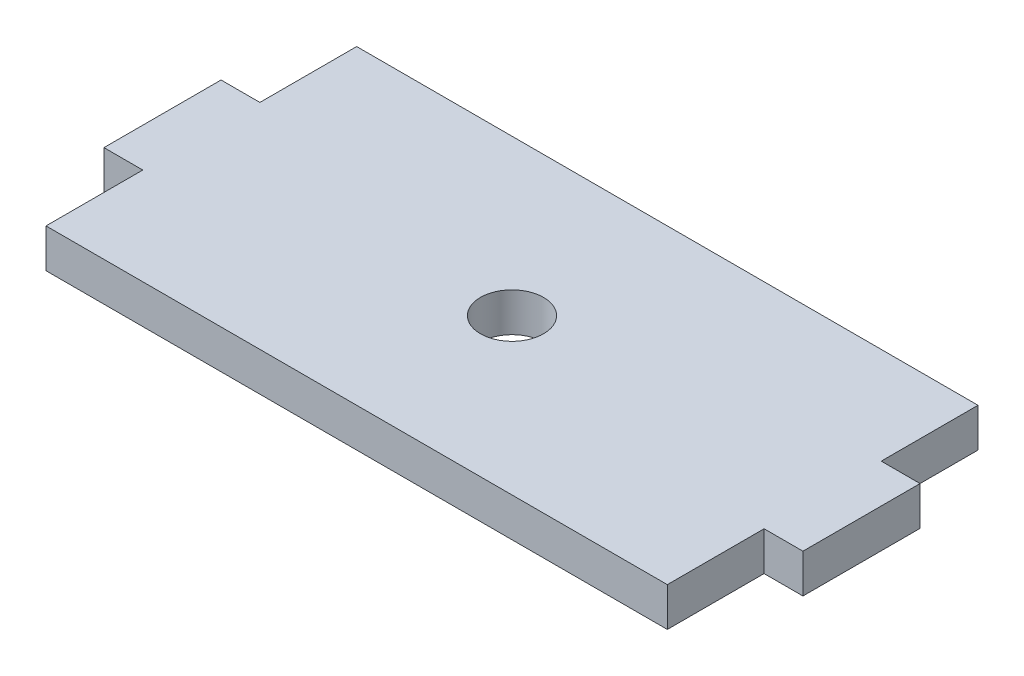
from build123d import *

# Parameters (mm, degrees)
SKETCH1_R           = 2.5796875
BOSS_EXTRUDE1_DEPTH = 1.5875


with BuildPart() as part:
    # Sketch1 → Boss-Extrude1 (new body, symmetric)
    with BuildSketch(Plane(origin=(0, 0, 0), x_dir=(1, 0, 0), z_dir=(0, 1, 0))):
        Polygon((25.4, -4.7879), (25.4, -12.7), (-25.4, -12.7), (-25.4, -4.7879), (-28.575, -4.7879), (-28.575, 4.7879), (-25.4, 4.7879), (-25.4, 12.7), (25.4, 12.7), (25.4, 4.7879), (28.575, 4.7879), (28.575, -4.7879), align=None)
        Circle(SKETCH1_R, mode=Mode.SUBTRACT)
    extrude(amount=BOSS_EXTRUDE1_DEPTH, both=True)


solid = part.part
